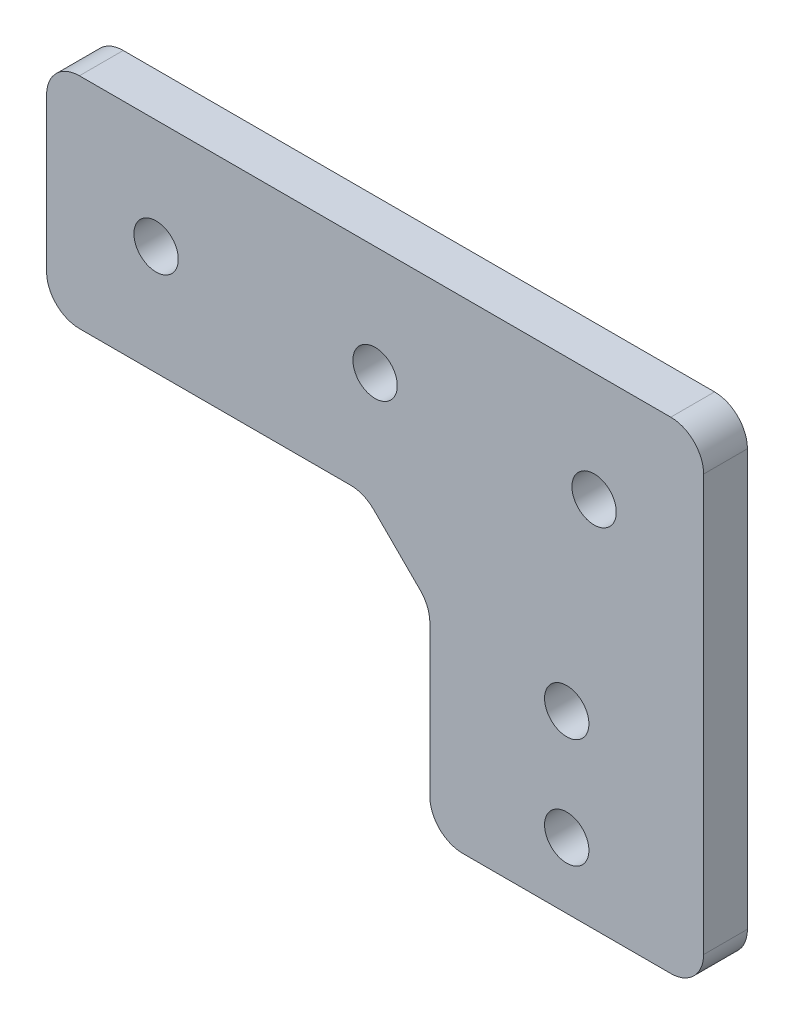
from build123d import *

# Parameters (mm, degrees)
EXTRUDE_1_DEPTH          = 4
EXTRUDE_2_DEPTH          = 4
SKETCH_3_R               = 5
CUT_EXTRUDE_1_DEPTH      = 4
SKETCH_6_W               = 25
SKETCH_6_H               = 6
CUT_EXTRUDE_4_DEPTH      = 1
CUT_EXTRUDE_4_DEPTH_BACK = 5
SKETCH_7_R               = 2.025
CUT_EXTRUDE_5_DEPTH      = 1
CUT_EXTRUDE_5_DEPTH_BACK = 5
SKETCH_9_R               = 5
EXTRUDE_3_DEPTH          = 4
SKETCH_12_R              = 2.025
CUT_EXTRUDE_8_DEPTH      = 1
CUT_EXTRUDE_8_DEPTH_BACK = 5
CUT_EXTRUDE_9_DEPTH      = 1
CUT_EXTRUDE_9_DEPTH_BACK = 5
EXTRUDE_4_DEPTH          = 4
FILLET_1_R               = 3


with BuildPart() as part:
    # 草图1 → 凸台-拉伸1 (new body)
    with BuildSketch(Plane.XY):
        Polygon((-35, 0), (0, 0), (0, -30), (25, -30), (25, 20), (-35, 20), align=None)
    extrude(amount=EXTRUDE_1_DEPTH)

    # 草图2 → 凸台-拉伸2 (add)
    with BuildSketch(Plane(origin=(0, 0, 0), x_dir=(-1, 0, 0), z_dir=(0, 0, -1))):
        with BuildLine():
            Line((-15.347247215, 38.473341973), (-25, 20))
            Line((-25, 20), (7.6, 20))
            Line((7.6, 20), (-2.052752785, 38.473341973))
            ThreePointArc((-2.052752785, 38.473341973), (-8.7, 42.5), (-15.347247215, 38.473341973))
        make_face()
    extrude(amount=-EXTRUDE_2_DEPTH)

    # 草图3 → 切除-拉伸1 (cut)
    with BuildSketch(Plane(origin=(0, 0, 0), x_dir=(-1, 0, 0), z_dir=(0, 0, -1))):
        with Locations((-8.7, 35)):
            Circle(SKETCH_3_R)
    extrude(amount=-CUT_EXTRUDE_1_DEPTH, mode=Mode.SUBTRACT)

    # 草图6 → 切除-拉伸4 (cut, two sides)
    with BuildSketch(Plane(origin=(0, 0, 0), x_dir=(-1, 0, 0), z_dir=(0, 0, -1))) as cut_extrude_4_sk:
        with Locations((-12.5, -27)):
            Rectangle(SKETCH_6_W, SKETCH_6_H)
    extrude(amount=CUT_EXTRUDE_4_DEPTH, mode=Mode.SUBTRACT)
    extrude(cut_extrude_4_sk.sketch, amount=-CUT_EXTRUDE_4_DEPTH_BACK, mode=Mode.SUBTRACT)

    # 草图7 → 切除-拉伸5 (cut, two sides)
    with BuildSketch(Plane(origin=(0, 0, 0), x_dir=(-1, 0, 0), z_dir=(0, 0, -1))) as cut_extrude_5_sk:
        with Locations((-12.5, -8)):
            Circle(SKETCH_7_R)
        with Locations((-12.5, -18)):
            Circle(SKETCH_7_R)
    extrude(amount=CUT_EXTRUDE_5_DEPTH, mode=Mode.SUBTRACT)
    extrude(cut_extrude_5_sk.sketch, amount=-CUT_EXTRUDE_5_DEPTH_BACK, mode=Mode.SUBTRACT)

    # 草图9 → 凸台-拉伸3 (add)
    with BuildSketch(Plane(origin=(0, 0, 0), x_dir=(-1, 0, 0), z_dir=(0, 0, -1))):
        with BuildLine():
            Line((-20.878399595, 37.817194226), (-25, 20))
            Line((-25, 20), (7.6, 20))
            Line((7.6, 20), (3.478399595, 37.817194226))
            ThreePointArc((3.478399595, 37.817194226), (-8.7, 47.5), (-20.878399595, 37.817194226))
        make_face()
        with Locations((-8.7, 35)):
            Circle(SKETCH_9_R, mode=Mode.SUBTRACT)
    extrude(amount=-EXTRUDE_3_DEPTH)

    # 草图12 → 切除-拉伸8 (cut, two sides)
    with BuildSketch(Plane(origin=(0, 0, 0), x_dir=(-1, 0, 0), z_dir=(0, 0, -1))) as cut_extrude_8_sk:
        with Locations((-15, 10)):
            Circle(SKETCH_12_R)
        with Locations((5, 10)):
            Circle(SKETCH_12_R)
        with Locations((25, 10)):
            Circle(SKETCH_12_R)
    extrude(amount=CUT_EXTRUDE_8_DEPTH, mode=Mode.SUBTRACT)
    extrude(cut_extrude_8_sk.sketch, amount=-CUT_EXTRUDE_8_DEPTH_BACK, mode=Mode.SUBTRACT)

    # 草图13 → 切除-拉伸9 (cut, two sides)
    with BuildSketch(Plane(origin=(0, 0, 0), x_dir=(-1, 0, 0), z_dir=(0, 0, -1))) as cut_extrude_9_sk:
        with BuildLine():
            Line((-25, 20), (7.6, 20))
            Line((7.6, 20), (3.478399595, 37.817194226))
            ThreePointArc((3.478399595, 37.817194226), (-8.7, 47.5), (-20.878399595, 37.817194226))
            Line((-20.878399595, 37.817194226), (-25, 20))
        make_face()
    extrude(amount=CUT_EXTRUDE_9_DEPTH, mode=Mode.SUBTRACT)
    extrude(cut_extrude_9_sk.sketch, amount=-CUT_EXTRUDE_9_DEPTH_BACK, mode=Mode.SUBTRACT)

    # 草图14 → 凸台-拉伸4 (add)
    with BuildSketch(Plane(origin=(0, 0, 0), x_dir=(-1, 0, 0), z_dir=(0, 0, -1))):
        Polygon((0, -6), (6, 0), (0, 0), align=None)
    extrude(amount=-EXTRUDE_4_DEPTH)

    # 圆角1
    fillet_1_edges = [part.edges().sort_by_distance(p)[0] for p in [
        (-35, 20, 2),
        (25, 20, 2),
        (-35, 0, 2),
        (-6, 0, 2),
        (0, -6, 2),
        (25, -24, 2),
        (0, -24, 2),
    ]]
    fillet(fillet_1_edges, radius=FILLET_1_R)


solid = part.part
